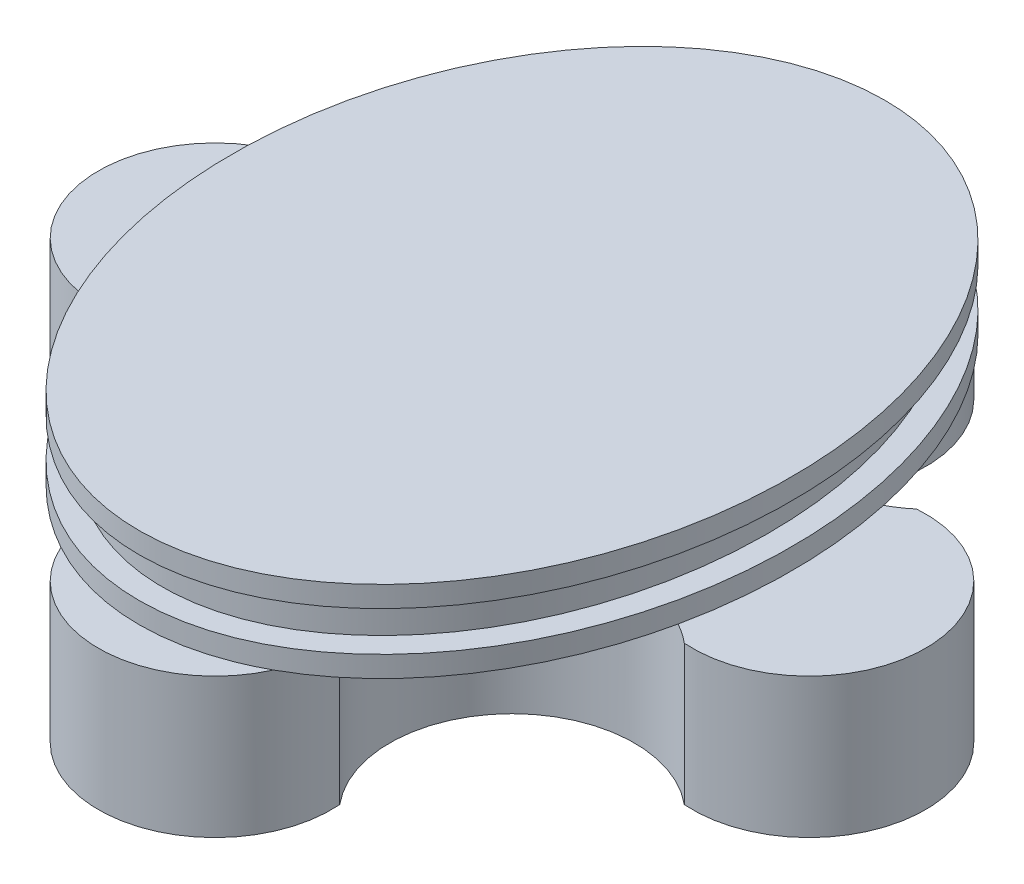
from build123d import *

# Parameters (mm, degrees)
SKETCH1_RX          = 16
SKETCH1_RY          = 12
BOSS_EXTRUDE1_DEPTH = 0.9
BOSS_EXTRUDE2_DEPTH = 6
SKETCH4_R           = 3
CUT_EXTRUDE1_DEPTH  = 10
SKETCH5_RX          = 15
SKETCH5_RY          = 11
BOSS_EXTRUDE3_DEPTH = 1.7
SKETCH6_RX          = 16
SKETCH6_RY          = 12
BOSS_EXTRUDE4_DEPTH = 0.9


with BuildPart() as part:
    # Sketch1 → Boss-Extrude1 (new body)
    with BuildSketch(Plane(origin=(0, 0, 0), x_dir=(1, 0, 0), z_dir=(0, 1, 0))):
        with Locations(Location((0, 0), (0, 0, 90))):
            Ellipse(SKETCH1_RX, SKETCH1_RY)
    extrude(amount=BOSS_EXTRUDE1_DEPTH)

    # Sketch3 → Boss-Extrude2 (add)
    with BuildSketch(Plane(origin=(0, 0, 0), x_dir=(-1, 0, 0), z_dir=(0, -1, 0))):
        with BuildLine():
            ThreePointArc((12.379824796, -4.986278203), (17.749999782, -0.001477913), (12.382772576, 4.986496167))
            ThreePointArc((12.382772576, 4.986496167), (5.304706978, 5.301894868), (4.986278203, 12.379824796))
            ThreePointArc((4.986278203, 12.379824796), (0.001477913, 17.749999782), (-4.986496167, 12.382772576))
            ThreePointArc((-4.986496167, 12.382772576), (-5.301894868, 5.304706978), (-12.379824796, 4.986278203))
            ThreePointArc((-12.379824796, 4.986278203), (-17.749999782, 0.001477913), (-12.382772576, -4.986496167))
            ThreePointArc((-12.382772576, -4.986496167), (-5.304706978, -5.301894868), (-4.986278203, -12.379824796))
            ThreePointArc((-4.986278203, -12.379824796), (-0.001477913, -17.749999782), (4.986496167, -12.382772576))
            ThreePointArc((4.986496167, -12.382772576), (5.301894868, -5.304706978), (12.379824796, -4.986278203))
        make_face()
    extrude(amount=BOSS_EXTRUDE2_DEPTH)

    # Sketch4 → Cut-Extrude1 (cut)
    with BuildSketch(Plane(origin=(0, 0.9, 0), x_dir=(1, 0, 0), z_dir=(0, 1, 0))):
        Circle(SKETCH4_R)
    extrude(amount=-CUT_EXTRUDE1_DEPTH, mode=Mode.SUBTRACT)

    # Sketch5 → Boss-Extrude3 (add)
    with BuildSketch(Plane(origin=(0, 0.9, 0), x_dir=(1, 0, 0), z_dir=(0, 1, 0))):
        with Locations(Location((0, 0), (0, 0, 90))):
            Ellipse(SKETCH5_RX, SKETCH5_RY)
    extrude(amount=BOSS_EXTRUDE3_DEPTH)

    # Sketch6 → Boss-Extrude4 (add)
    with BuildSketch(Plane(origin=(0, 2.6, 0), x_dir=(1, 0, 0), z_dir=(0, 1, 0))):
        with Locations(Location((0, 0), (0, 0, 90))):
            Ellipse(SKETCH6_RX, SKETCH6_RY)
    extrude(amount=BOSS_EXTRUDE4_DEPTH)


solid = part.part
